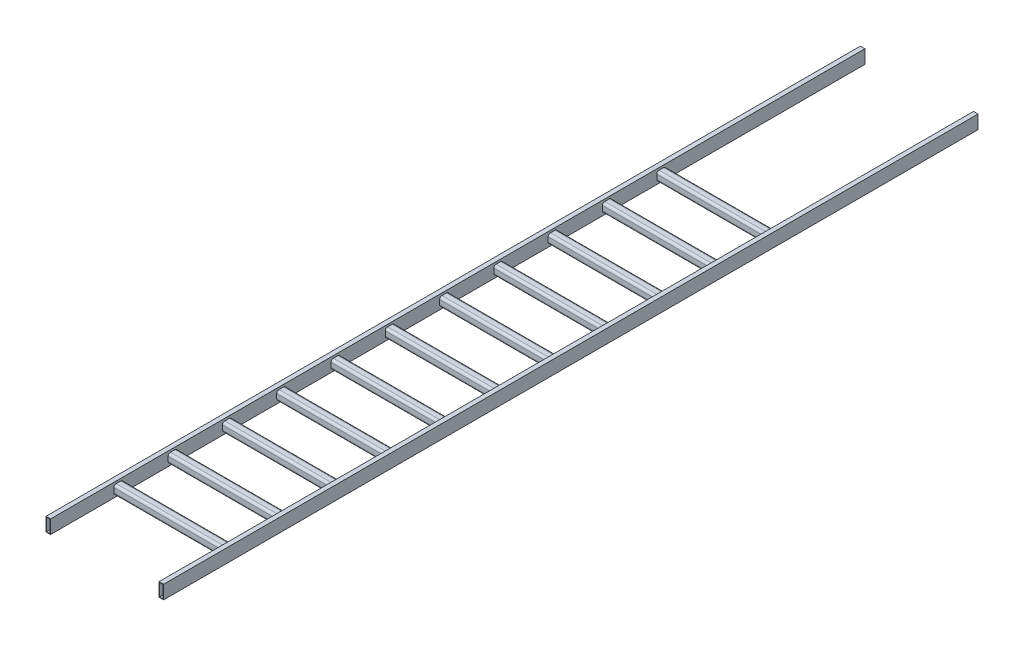
from build123d import *

# Parameters (mm, degrees)
SKETCH15_W                          = 25.4
SKETCH15_H                          = 76.2
SKETCH15_W_2                        = 19.05
SKETCH15_H_2                        = 69.85
BOSS_EXTRUDE1_DEPTH                 = 4572
BOSS_EXTRUDE1_2_DEPTH               = 4572
SQUARE_TUBE_2_X_2_X_0_25_3_DEPTH    = 609.6
SQUARE_TUBE_2_X_2_X_0_25_3_2_DEPTH  = 609.6
SQUARE_TUBE_2_X_2_X_0_25_3_3_DEPTH  = 609.6
SQUARE_TUBE_2_X_2_X_0_25_3_4_DEPTH  = 609.6
SQUARE_TUBE_2_X_2_X_0_25_3_5_DEPTH  = 609.6
SQUARE_TUBE_2_X_2_X_0_25_3_6_DEPTH  = 609.6
SQUARE_TUBE_2_X_2_X_0_25_3_7_DEPTH  = 609.6
SQUARE_TUBE_2_X_2_X_0_25_3_8_DEPTH  = 609.6
SQUARE_TUBE_2_X_2_X_0_25_3_9_DEPTH  = 609.6
SQUARE_TUBE_2_X_2_X_0_25_3_10_DEPTH = 609.6
SQUARE_TUBE_2_X_2_X_0_25_3_11_DEPTH = 609.6
SKETCH115_W                         = 101.6
SKETCH115_H                         = 25.4
BOSS_EXTRUDE2_DEPTH                 = 0.00254
BOSS_EXTRUDE2_2_DEPTH               = 0.00254


with BuildPart() as part:
    # Sketch15 → Boss-Extrude1 (new body)
    with BuildSketch(Plane.XY):
        with Locations((-317.5, 0)):
            Rectangle(SKETCH15_W, SKETCH15_H)
        with Locations((-317.5, 0)):
            Rectangle(SKETCH15_W_2, SKETCH15_H_2, mode=Mode.SUBTRACT)
    extrude(amount=BOSS_EXTRUDE1_DEPTH)


with BuildPart() as body_2:
    # Sketch15 → Boss-Extrude1 2 (new body)
    with BuildSketch(Plane.XY):
        with Locations((317.5, 0)):
            Rectangle(SKETCH15_W, SKETCH15_H)
        with Locations((317.5, 0)):
            Rectangle(SKETCH15_W_2, SKETCH15_H_2, mode=Mode.SUBTRACT)
    extrude(amount=BOSS_EXTRUDE1_2_DEPTH)


with BuildPart() as body_3:
    # Sketch1 → Square tube 2 X 2 X 0.25(3) (new body)
    with BuildSketch(Plane(origin=(-304.8, 0, 1143), x_dir=(0, 0, -1), z_dir=(1, 0, 0))):
        with BuildLine():
            Line((-12.7, -25.4), (12.7, -25.4))
            ThreePointArc((12.7, -25.4), (21.680256121, -21.680256121), (25.4, -12.7))
            Line((25.4, -12.7), (25.4, 12.7))
            ThreePointArc((25.4, 12.7), (21.680256121, 21.680256121), (12.7, 25.4))
            Line((12.7, 25.4), (-12.7, 25.4))
            ThreePointArc((-12.7, 25.4), (-21.680256121, 21.680256121), (-25.4, 12.7))
            Line((-25.4, 12.7), (-25.4, -12.7))
            ThreePointArc((-25.4, -12.7), (-21.680256121, -21.680256121), (-12.7, -25.4))
        make_face()
        with BuildLine():
            Line((-12.7, -19.05), (12.7, -19.05))
            ThreePointArc((12.7, -19.05), (17.190128061, -17.190128061), (19.05, -12.7))
            Line((19.05, -12.7), (19.05, 12.7))
            ThreePointArc((19.05, 12.7), (17.190128061, 17.190128061), (12.7, 19.05))
            Line((12.7, 19.05), (-12.7, 19.05))
            ThreePointArc((-12.7, 19.05), (-17.190128061, 17.190128061), (-19.05, 12.7))
            Line((-19.05, 12.7), (-19.05, -12.7))
            ThreePointArc((-19.05, -12.7), (-17.190128061, -17.190128061), (-12.7, -19.05))
        make_face(mode=Mode.SUBTRACT)
    extrude(amount=SQUARE_TUBE_2_X_2_X_0_25_3_DEPTH)


with BuildPart() as body_4:
    # Sketch1 on segment 2 (carried to segment 2) → Square tube 2 X 2 X 0.25_3 2 (new body)
    with BuildSketch(Plane(origin=(-304.8, 0, 1447.8), x_dir=(0, 0, -1), z_dir=(1, 0, 0))):
        with BuildLine():
            Line((-12.7, -25.4), (12.7, -25.4))
            ThreePointArc((12.7, -25.4), (21.680256121, -21.680256121), (25.4, -12.7))
            Line((25.4, -12.7), (25.4, 12.7))
            ThreePointArc((25.4, 12.7), (21.680256121, 21.680256121), (12.7, 25.4))
            Line((12.7, 25.4), (-12.7, 25.4))
            ThreePointArc((-12.7, 25.4), (-21.680256121, 21.680256121), (-25.4, 12.7))
            Line((-25.4, 12.7), (-25.4, -12.7))
            ThreePointArc((-25.4, -12.7), (-21.680256121, -21.680256121), (-12.7, -25.4))
        make_face()
        with BuildLine():
            Line((-12.7, -19.05), (12.7, -19.05))
            ThreePointArc((12.7, -19.05), (17.190128061, -17.190128061), (19.05, -12.7))
            Line((19.05, -12.7), (19.05, 12.7))
            ThreePointArc((19.05, 12.7), (17.190128061, 17.190128061), (12.7, 19.05))
            Line((12.7, 19.05), (-12.7, 19.05))
            ThreePointArc((-12.7, 19.05), (-17.190128061, 17.190128061), (-19.05, 12.7))
            Line((-19.05, 12.7), (-19.05, -12.7))
            ThreePointArc((-19.05, -12.7), (-17.190128061, -17.190128061), (-12.7, -19.05))
        make_face(mode=Mode.SUBTRACT)
    extrude(amount=SQUARE_TUBE_2_X_2_X_0_25_3_2_DEPTH)


with BuildPart() as body_5:
    # Sketch1 on segment 3 (carried to segment 3) → Square tube 2 X 2 X 0.25_3 3 (new body)
    with BuildSketch(Plane(origin=(-304.8, 0, 1752.6), x_dir=(0, 0, -1), z_dir=(1, 0, 0))):
        with BuildLine():
            Line((-12.7, -25.4), (12.7, -25.4))
            ThreePointArc((12.7, -25.4), (21.680256121, -21.680256121), (25.4, -12.7))
            Line((25.4, -12.7), (25.4, 12.7))
            ThreePointArc((25.4, 12.7), (21.680256121, 21.680256121), (12.7, 25.4))
            Line((12.7, 25.4), (-12.7, 25.4))
            ThreePointArc((-12.7, 25.4), (-21.680256121, 21.680256121), (-25.4, 12.7))
            Line((-25.4, 12.7), (-25.4, -12.7))
            ThreePointArc((-25.4, -12.7), (-21.680256121, -21.680256121), (-12.7, -25.4))
        make_face()
        with BuildLine():
            Line((-12.7, -19.05), (12.7, -19.05))
            ThreePointArc((12.7, -19.05), (17.190128061, -17.190128061), (19.05, -12.7))
            Line((19.05, -12.7), (19.05, 12.7))
            ThreePointArc((19.05, 12.7), (17.190128061, 17.190128061), (12.7, 19.05))
            Line((12.7, 19.05), (-12.7, 19.05))
            ThreePointArc((-12.7, 19.05), (-17.190128061, 17.190128061), (-19.05, 12.7))
            Line((-19.05, 12.7), (-19.05, -12.7))
            ThreePointArc((-19.05, -12.7), (-17.190128061, -17.190128061), (-12.7, -19.05))
        make_face(mode=Mode.SUBTRACT)
    extrude(amount=SQUARE_TUBE_2_X_2_X_0_25_3_3_DEPTH)


with BuildPart() as body_6:
    # Sketch1 on segment 4 (carried to segment 4) → Square tube 2 X 2 X 0.25_3 4 (new body)
    with BuildSketch(Plane(origin=(-304.8, 0, 2057.4), x_dir=(0, 0, -1), z_dir=(1, 0, 0))):
        with BuildLine():
            Line((-12.7, -25.4), (12.7, -25.4))
            ThreePointArc((12.7, -25.4), (21.680256121, -21.680256121), (25.4, -12.7))
            Line((25.4, -12.7), (25.4, 12.7))
            ThreePointArc((25.4, 12.7), (21.680256121, 21.680256121), (12.7, 25.4))
            Line((12.7, 25.4), (-12.7, 25.4))
            ThreePointArc((-12.7, 25.4), (-21.680256121, 21.680256121), (-25.4, 12.7))
            Line((-25.4, 12.7), (-25.4, -12.7))
            ThreePointArc((-25.4, -12.7), (-21.680256121, -21.680256121), (-12.7, -25.4))
        make_face()
        with BuildLine():
            Line((-12.7, -19.05), (12.7, -19.05))
            ThreePointArc((12.7, -19.05), (17.190128061, -17.190128061), (19.05, -12.7))
            Line((19.05, -12.7), (19.05, 12.7))
            ThreePointArc((19.05, 12.7), (17.190128061, 17.190128061), (12.7, 19.05))
            Line((12.7, 19.05), (-12.7, 19.05))
            ThreePointArc((-12.7, 19.05), (-17.190128061, 17.190128061), (-19.05, 12.7))
            Line((-19.05, 12.7), (-19.05, -12.7))
            ThreePointArc((-19.05, -12.7), (-17.190128061, -17.190128061), (-12.7, -19.05))
        make_face(mode=Mode.SUBTRACT)
    extrude(amount=SQUARE_TUBE_2_X_2_X_0_25_3_4_DEPTH)


with BuildPart() as body_7:
    # Sketch1 on segment 5 (carried to segment 5) → Square tube 2 X 2 X 0.25_3 5 (new body)
    with BuildSketch(Plane(origin=(-304.8, 0, 2667), x_dir=(0, 0, -1), z_dir=(1, 0, 0))):
        with BuildLine():
            Line((-12.7, -25.4), (12.7, -25.4))
            ThreePointArc((12.7, -25.4), (21.680256121, -21.680256121), (25.4, -12.7))
            Line((25.4, -12.7), (25.4, 12.7))
            ThreePointArc((25.4, 12.7), (21.680256121, 21.680256121), (12.7, 25.4))
            Line((12.7, 25.4), (-12.7, 25.4))
            ThreePointArc((-12.7, 25.4), (-21.680256121, 21.680256121), (-25.4, 12.7))
            Line((-25.4, 12.7), (-25.4, -12.7))
            ThreePointArc((-25.4, -12.7), (-21.680256121, -21.680256121), (-12.7, -25.4))
        make_face()
        with BuildLine():
            Line((-12.7, -19.05), (12.7, -19.05))
            ThreePointArc((12.7, -19.05), (17.190128061, -17.190128061), (19.05, -12.7))
            Line((19.05, -12.7), (19.05, 12.7))
            ThreePointArc((19.05, 12.7), (17.190128061, 17.190128061), (12.7, 19.05))
            Line((12.7, 19.05), (-12.7, 19.05))
            ThreePointArc((-12.7, 19.05), (-17.190128061, 17.190128061), (-19.05, 12.7))
            Line((-19.05, 12.7), (-19.05, -12.7))
            ThreePointArc((-19.05, -12.7), (-17.190128061, -17.190128061), (-12.7, -19.05))
        make_face(mode=Mode.SUBTRACT)
    extrude(amount=SQUARE_TUBE_2_X_2_X_0_25_3_5_DEPTH)


with BuildPart() as body_8:
    # Sketch1 on segment 6 (carried to segment 6) → Square tube 2 X 2 X 0.25_3 6 (new body)
    with BuildSketch(Plane(origin=(-304.8, 0, 2362.2), x_dir=(0, 0, -1), z_dir=(1, 0, 0))):
        with BuildLine():
            Line((-12.7, -25.4), (12.7, -25.4))
            ThreePointArc((12.7, -25.4), (21.680256121, -21.680256121), (25.4, -12.7))
            Line((25.4, -12.7), (25.4, 12.7))
            ThreePointArc((25.4, 12.7), (21.680256121, 21.680256121), (12.7, 25.4))
            Line((12.7, 25.4), (-12.7, 25.4))
            ThreePointArc((-12.7, 25.4), (-21.680256121, 21.680256121), (-25.4, 12.7))
            Line((-25.4, 12.7), (-25.4, -12.7))
            ThreePointArc((-25.4, -12.7), (-21.680256121, -21.680256121), (-12.7, -25.4))
        make_face()
        with BuildLine():
            Line((-12.7, -19.05), (12.7, -19.05))
            ThreePointArc((12.7, -19.05), (17.190128061, -17.190128061), (19.05, -12.7))
            Line((19.05, -12.7), (19.05, 12.7))
            ThreePointArc((19.05, 12.7), (17.190128061, 17.190128061), (12.7, 19.05))
            Line((12.7, 19.05), (-12.7, 19.05))
            ThreePointArc((-12.7, 19.05), (-17.190128061, 17.190128061), (-19.05, 12.7))
            Line((-19.05, 12.7), (-19.05, -12.7))
            ThreePointArc((-19.05, -12.7), (-17.190128061, -17.190128061), (-12.7, -19.05))
        make_face(mode=Mode.SUBTRACT)
    extrude(amount=SQUARE_TUBE_2_X_2_X_0_25_3_6_DEPTH)


with BuildPart() as body_9:
    # Sketch1 on segment 7 (carried to segment 7) → Square tube 2 X 2 X 0.25_3 7 (new body)
    with BuildSketch(Plane(origin=(-304.8, 0, 2971.8), x_dir=(0, 0, -1), z_dir=(1, 0, 0))):
        with BuildLine():
            Line((-12.7, -25.4), (12.7, -25.4))
            ThreePointArc((12.7, -25.4), (21.680256121, -21.680256121), (25.4, -12.7))
            Line((25.4, -12.7), (25.4, 12.7))
            ThreePointArc((25.4, 12.7), (21.680256121, 21.680256121), (12.7, 25.4))
            Line((12.7, 25.4), (-12.7, 25.4))
            ThreePointArc((-12.7, 25.4), (-21.680256121, 21.680256121), (-25.4, 12.7))
            Line((-25.4, 12.7), (-25.4, -12.7))
            ThreePointArc((-25.4, -12.7), (-21.680256121, -21.680256121), (-12.7, -25.4))
        make_face()
        with BuildLine():
            Line((-12.7, -19.05), (12.7, -19.05))
            ThreePointArc((12.7, -19.05), (17.190128061, -17.190128061), (19.05, -12.7))
            Line((19.05, -12.7), (19.05, 12.7))
            ThreePointArc((19.05, 12.7), (17.190128061, 17.190128061), (12.7, 19.05))
            Line((12.7, 19.05), (-12.7, 19.05))
            ThreePointArc((-12.7, 19.05), (-17.190128061, 17.190128061), (-19.05, 12.7))
            Line((-19.05, 12.7), (-19.05, -12.7))
            ThreePointArc((-19.05, -12.7), (-17.190128061, -17.190128061), (-12.7, -19.05))
        make_face(mode=Mode.SUBTRACT)
    extrude(amount=SQUARE_TUBE_2_X_2_X_0_25_3_7_DEPTH)


with BuildPart() as body_10:
    # Sketch1 on segment 8 (carried to segment 8) → Square tube 2 X 2 X 0.25_3 8 (new body)
    with BuildSketch(Plane(origin=(-304.8, 0, 3276.6), x_dir=(0, 0, -1), z_dir=(1, 0, 0))):
        with BuildLine():
            Line((-12.7, -25.4), (12.7, -25.4))
            ThreePointArc((12.7, -25.4), (21.680256121, -21.680256121), (25.4, -12.7))
            Line((25.4, -12.7), (25.4, 12.7))
            ThreePointArc((25.4, 12.7), (21.680256121, 21.680256121), (12.7, 25.4))
            Line((12.7, 25.4), (-12.7, 25.4))
            ThreePointArc((-12.7, 25.4), (-21.680256121, 21.680256121), (-25.4, 12.7))
            Line((-25.4, 12.7), (-25.4, -12.7))
            ThreePointArc((-25.4, -12.7), (-21.680256121, -21.680256121), (-12.7, -25.4))
        make_face()
        with BuildLine():
            Line((-12.7, -19.05), (12.7, -19.05))
            ThreePointArc((12.7, -19.05), (17.190128061, -17.190128061), (19.05, -12.7))
            Line((19.05, -12.7), (19.05, 12.7))
            ThreePointArc((19.05, 12.7), (17.190128061, 17.190128061), (12.7, 19.05))
            Line((12.7, 19.05), (-12.7, 19.05))
            ThreePointArc((-12.7, 19.05), (-17.190128061, 17.190128061), (-19.05, 12.7))
            Line((-19.05, 12.7), (-19.05, -12.7))
            ThreePointArc((-19.05, -12.7), (-17.190128061, -17.190128061), (-12.7, -19.05))
        make_face(mode=Mode.SUBTRACT)
    extrude(amount=SQUARE_TUBE_2_X_2_X_0_25_3_8_DEPTH)


with BuildPart() as body_11:
    # Sketch1 on segment 9 (carried to segment 9) → Square tube 2 X 2 X 0.25_3 9 (new body)
    with BuildSketch(Plane(origin=(-304.8, 0, 3581.4), x_dir=(0, 0, -1), z_dir=(1, 0, 0))):
        with BuildLine():
            Line((-12.7, -25.4), (12.7, -25.4))
            ThreePointArc((12.7, -25.4), (21.680256121, -21.680256121), (25.4, -12.7))
            Line((25.4, -12.7), (25.4, 12.7))
            ThreePointArc((25.4, 12.7), (21.680256121, 21.680256121), (12.7, 25.4))
            Line((12.7, 25.4), (-12.7, 25.4))
            ThreePointArc((-12.7, 25.4), (-21.680256121, 21.680256121), (-25.4, 12.7))
            Line((-25.4, 12.7), (-25.4, -12.7))
            ThreePointArc((-25.4, -12.7), (-21.680256121, -21.680256121), (-12.7, -25.4))
        make_face()
        with BuildLine():
            Line((-12.7, -19.05), (12.7, -19.05))
            ThreePointArc((12.7, -19.05), (17.190128061, -17.190128061), (19.05, -12.7))
            Line((19.05, -12.7), (19.05, 12.7))
            ThreePointArc((19.05, 12.7), (17.190128061, 17.190128061), (12.7, 19.05))
            Line((12.7, 19.05), (-12.7, 19.05))
            ThreePointArc((-12.7, 19.05), (-17.190128061, 17.190128061), (-19.05, 12.7))
            Line((-19.05, 12.7), (-19.05, -12.7))
            ThreePointArc((-19.05, -12.7), (-17.190128061, -17.190128061), (-12.7, -19.05))
        make_face(mode=Mode.SUBTRACT)
    extrude(amount=SQUARE_TUBE_2_X_2_X_0_25_3_9_DEPTH)


with BuildPart() as body_12:
    # Sketch1 on segment 10 (carried to segment 10) → Square tube 2 X 2 X 0.25_3 10 (new body)
    with BuildSketch(Plane(origin=(-304.8, 0, 3886.2), x_dir=(0, 0, -1), z_dir=(1, 0, 0))):
        with BuildLine():
            Line((-12.7, -25.4), (12.7, -25.4))
            ThreePointArc((12.7, -25.4), (21.680256121, -21.680256121), (25.4, -12.7))
            Line((25.4, -12.7), (25.4, 12.7))
            ThreePointArc((25.4, 12.7), (21.680256121, 21.680256121), (12.7, 25.4))
            Line((12.7, 25.4), (-12.7, 25.4))
            ThreePointArc((-12.7, 25.4), (-21.680256121, 21.680256121), (-25.4, 12.7))
            Line((-25.4, 12.7), (-25.4, -12.7))
            ThreePointArc((-25.4, -12.7), (-21.680256121, -21.680256121), (-12.7, -25.4))
        make_face()
        with BuildLine():
            Line((-12.7, -19.05), (12.7, -19.05))
            ThreePointArc((12.7, -19.05), (17.190128061, -17.190128061), (19.05, -12.7))
            Line((19.05, -12.7), (19.05, 12.7))
            ThreePointArc((19.05, 12.7), (17.190128061, 17.190128061), (12.7, 19.05))
            Line((12.7, 19.05), (-12.7, 19.05))
            ThreePointArc((-12.7, 19.05), (-17.190128061, 17.190128061), (-19.05, 12.7))
            Line((-19.05, 12.7), (-19.05, -12.7))
            ThreePointArc((-19.05, -12.7), (-17.190128061, -17.190128061), (-12.7, -19.05))
        make_face(mode=Mode.SUBTRACT)
    extrude(amount=SQUARE_TUBE_2_X_2_X_0_25_3_10_DEPTH)


with BuildPart() as body_13:
    # Sketch1 on segment 11 (carried to segment 11) → Square tube 2 X 2 X 0.25_3 11 (new body)
    with BuildSketch(Plane(origin=(-304.8, 0, 4191), x_dir=(0, 0, -1), z_dir=(1, 0, 0))):
        with BuildLine():
            Line((-12.7, -25.4), (12.7, -25.4))
            ThreePointArc((12.7, -25.4), (21.680256121, -21.680256121), (25.4, -12.7))
            Line((25.4, -12.7), (25.4, 12.7))
            ThreePointArc((25.4, 12.7), (21.680256121, 21.680256121), (12.7, 25.4))
            Line((12.7, 25.4), (-12.7, 25.4))
            ThreePointArc((-12.7, 25.4), (-21.680256121, 21.680256121), (-25.4, 12.7))
            Line((-25.4, 12.7), (-25.4, -12.7))
            ThreePointArc((-25.4, -12.7), (-21.680256121, -21.680256121), (-12.7, -25.4))
        make_face()
        with BuildLine():
            Line((-12.7, -19.05), (12.7, -19.05))
            ThreePointArc((12.7, -19.05), (17.190128061, -17.190128061), (19.05, -12.7))
            Line((19.05, -12.7), (19.05, 12.7))
            ThreePointArc((19.05, 12.7), (17.190128061, 17.190128061), (12.7, 19.05))
            Line((12.7, 19.05), (-12.7, 19.05))
            ThreePointArc((-12.7, 19.05), (-17.190128061, 17.190128061), (-19.05, 12.7))
            Line((-19.05, 12.7), (-19.05, -12.7))
            ThreePointArc((-19.05, -12.7), (-17.190128061, -17.190128061), (-12.7, -19.05))
        make_face(mode=Mode.SUBTRACT)
    extrude(amount=SQUARE_TUBE_2_X_2_X_0_25_3_11_DEPTH)


with BuildPart() as body_14:
    # Sketch115 → Boss-Extrude2 (new body)
    with BuildSketch(Plane(origin=(0, 0, 1117.6), x_dir=(-1, 0, 0), z_dir=(0, 0, -1))):
        with Locations((-152.4, 0)):
            Rectangle(SKETCH115_W, SKETCH115_H)
    extrude(amount=BOSS_EXTRUDE2_DEPTH)


with BuildPart() as body_15:
    # Sketch115 → Boss-Extrude2 2 (new body)
    with BuildSketch(Plane(origin=(0, 0, 1117.6), x_dir=(-1, 0, 0), z_dir=(0, 0, -1))):
        with Locations((152.4, 0)):
            Rectangle(SKETCH115_W, SKETCH115_H)
    extrude(amount=BOSS_EXTRUDE2_2_DEPTH)


solid = Compound([part.part, body_2.part, body_3.part, body_4.part, body_5.part, body_6.part, body_7.part, body_8.part, body_9.part, body_10.part, body_11.part, body_12.part, body_13.part, body_14.part, body_15.part])
